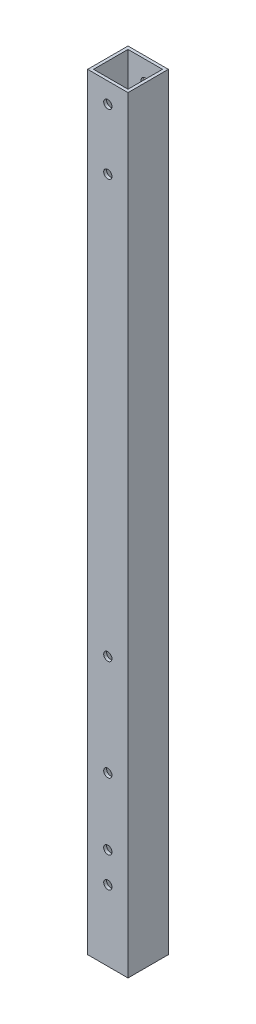
from build123d import *

# Parameters (mm, degrees)
SKETCH1_W           = 20
SKETCH1_H           = 20
SKETCH1_W_2         = 17.1
SKETCH1_H_2         = 17.1
BOSS_EXTRUDE1_DEPTH = 350
SKETCH2_R           = 2.05
CUT_EXTRUDE1_DEPTH  = 21
SKETCH3_R           = 2.05
CUT_EXTRUDE2_DEPTH  = 21
SKETCH4_W           = 20
SKETCH4_H           = 20
SKETCH4_W_2         = 17.1
SKETCH4_H_2         = 17.1
BOSS_EXTRUDE2_DEPTH = 30


with BuildPart() as part:
    # Sketch1 → Boss-Extrude1 (new body)
    with BuildSketch(Plane(origin=(0, 0, 0), x_dir=(1, 0, 0), z_dir=(0, 1, 0))):
        with Locations((10, 10)):
            Rectangle(SKETCH1_W, SKETCH1_H)
        with Locations((10, 10)):
            Rectangle(SKETCH1_W_2, SKETCH1_H_2, mode=Mode.SUBTRACT)
    extrude(amount=BOSS_EXTRUDE1_DEPTH)

    # Sketch2 → Cut-Extrude1 (cut, through all)
    with BuildSketch(Plane(origin=(0, 0, -20), x_dir=(-1, 0, 0), z_dir=(0, 0, -1))):
        with Locations((-10, 340)):
            Circle(SKETCH2_R)
        with Locations((-10, 310)):
            Circle(SKETCH2_R)
        with Locations((-10, 20)):
            Circle(SKETCH2_R)
        with Locations((-10, 5)):
            Circle(SKETCH2_R)
    extrude(amount=-CUT_EXTRUDE1_DEPTH, mode=Mode.SUBTRACT)

    # Sketch3 → Cut-Extrude2 (cut, through all)
    with BuildSketch(Plane(origin=(0, 0, -20), x_dir=(-1, 0, 0), z_dir=(0, 0, -1))):
        with Locations((-10, 103)):
            Circle(SKETCH3_R)
        with Locations((-10, 53)):
            Circle(SKETCH3_R)
    extrude(amount=-CUT_EXTRUDE2_DEPTH, mode=Mode.SUBTRACT)

    # Sketch4 → Boss-Extrude2 (add)
    with BuildSketch(Plane.XZ):
        with Locations((10, -10)):
            Rectangle(SKETCH4_W, SKETCH4_H)
        with Locations((10, -10)):
            Rectangle(SKETCH4_W_2, SKETCH4_H_2, mode=Mode.SUBTRACT)
    extrude(amount=BOSS_EXTRUDE2_DEPTH)


solid = part.part
